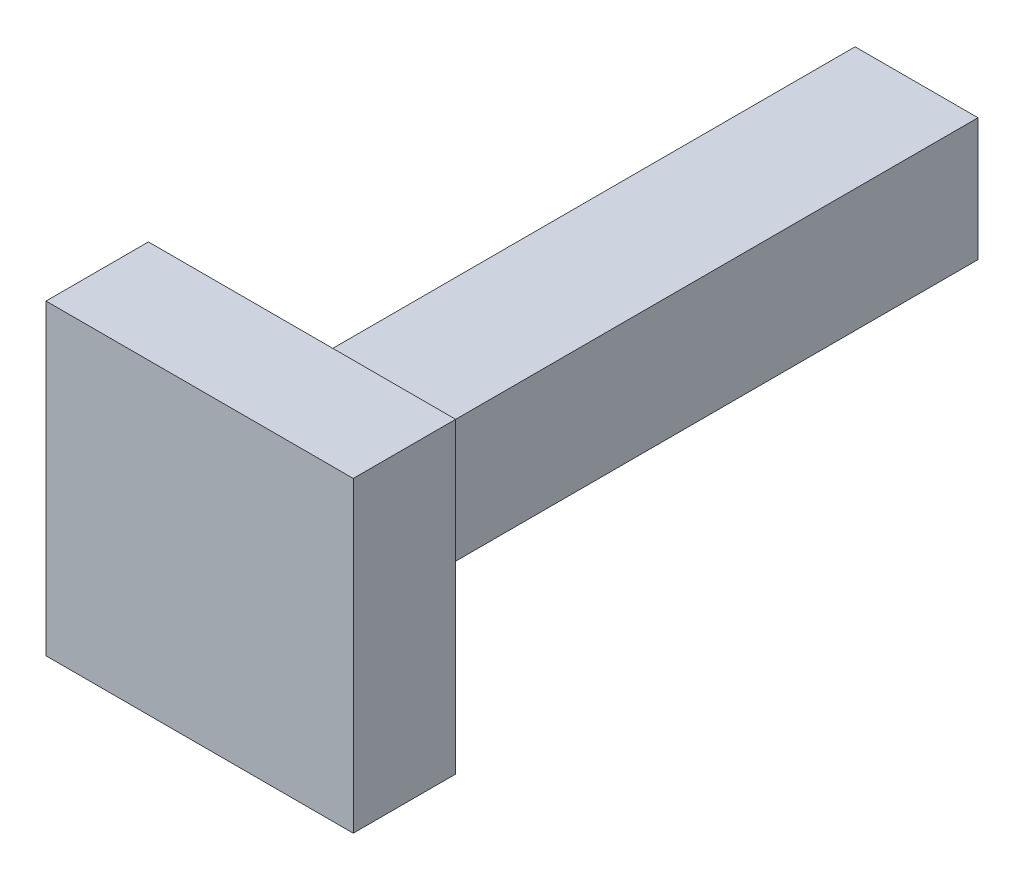
from build123d import *

# Parameters (mm, degrees)
SKETCH1_W           = 12
SKETCH1_H           = 12
BOSS_EXTRUDE1_DEPTH = 60
SKETCH2_W           = 30
SKETCH2_H           = 30
BOSS_EXTRUDE2_DEPTH = 10


with BuildPart() as part:
    # Sketch1 → Boss-Extrude1 (new body)
    with BuildSketch(Plane.XY):
        with Locations((6, 6)):
            Rectangle(SKETCH1_W, SKETCH1_H)
    extrude(amount=BOSS_EXTRUDE1_DEPTH)

    # Sketch2 → Boss-Extrude2 (add)
    with BuildSketch(Plane.XY.offset(60)):
        with Locations((6, 6)):
            Rectangle(SKETCH2_W, SKETCH2_H)
    extrude(amount=BOSS_EXTRUDE2_DEPTH)


solid = part.part
